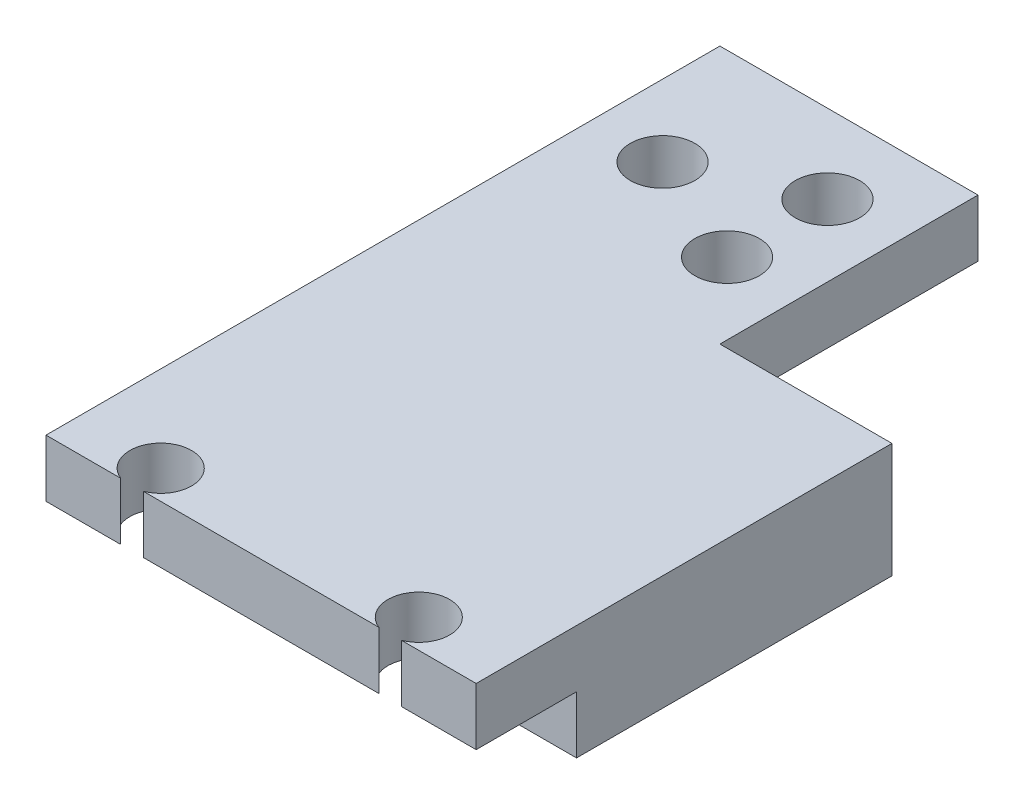
from build123d import *

# Parameters (mm, degrees)
BOSS_EXTRUDE1_DEPTH = 4
SKETCH2_W           = 30
SKETCH2_H           = 22
BOSS_EXTRUDE2_DEPTH = 4
SKETCH3_W           = 30
SKETCH3_H           = 4
BOSS_EXTRUDE3_DEPTH = 18
CUT_EXTRUDE1_REACH  = 6
SKETCH4_R           = 2.25
CUT_EXTRUDE2_REACH  = 6
SKETCH5_W           = 12
SKETCH5_H           = 18


with BuildPart() as part:
    # Sketch1 → Boss-Extrude1 (new body)
    with BuildSketch(Plane(origin=(0, 0, 0), x_dir=(1, 0, 0), z_dir=(0, 1, 0))):
        with BuildLine():
            Line((-15, -14.5), (-9.788986692, -14.5))
            ThreePointArc((-9.788986692, -14.5), (-9, -10.35), (-8.211013308, -14.5))
            Line((-8.211013308, -14.5), (8.211013308, -14.5))
            ThreePointArc((8.211013308, -14.5), (9, -10.35), (9.788986692, -14.5))
            Line((9.788986692, -14.5), (15, -14.5))
            Line((15, -14.5), (15, 14.5))
            Line((15, 14.5), (-15, 14.5))
            Line((-15, 14.5), (-15, -14.5))
        make_face()
    extrude(amount=BOSS_EXTRUDE1_DEPTH)

    # Sketch2 → Boss-Extrude2 (add)
    with BuildSketch(Plane.XZ):
        with Locations((0, -3.5)):
            Rectangle(SKETCH2_W, SKETCH2_H)
    extrude(amount=BOSS_EXTRUDE2_DEPTH)

    # Sketch3 → Boss-Extrude3 (add)
    with BuildSketch(Plane(origin=(0, 0, -14.5), x_dir=(-1, 0, 0), z_dir=(0, 0, -1))):
        with Locations((0, 2)):
            Rectangle(SKETCH3_W, SKETCH3_H)
    extrude(amount=BOSS_EXTRUDE3_DEPTH)

    # Sketch4 → Cut-Extrude1 (cut, up to next)
    with BuildSketch(Plane(origin=(0, 0, 0), x_dir=(-1, 0, 0), z_dir=(0, 1, 0)), mode=Mode.PRIVATE) as cut_extrude1_sk1:
        with Locations((2, -27)):
            Circle(SKETCH4_R)
    cut_extrude1_tool1 = extrude(cut_extrude1_sk1.sketch, amount=CUT_EXTRUDE1_REACH, mode=Mode.PRIVATE) & part.part
    add(cut_extrude1_tool1.solids().sort_by_distance((-2, 0, -27))[0], mode=Mode.SUBTRACT)
    # Sketch4 → Cut-Extrude1 (cut, up to next)
    with BuildSketch(Plane(origin=(0, 0, 0), x_dir=(-1, 0, 0), z_dir=(0, 1, 0)), mode=Mode.PRIVATE) as cut_extrude1_sk2:
        with Locations((10, -23.5)):
            Circle(SKETCH4_R)
    cut_extrude1_tool2 = extrude(cut_extrude1_sk2.sketch, amount=CUT_EXTRUDE1_REACH, mode=Mode.PRIVATE) & part.part
    add(cut_extrude1_tool2.solids().sort_by_distance((-10, 0, -23.5))[0], mode=Mode.SUBTRACT)
    # Sketch4 → Cut-Extrude1 (cut, up to next)
    with BuildSketch(Plane(origin=(0, 0, 0), x_dir=(-1, 0, 0), z_dir=(0, 1, 0)), mode=Mode.PRIVATE) as cut_extrude1_sk3:
        with Locations((2, -20)):
            Circle(SKETCH4_R)
    cut_extrude1_tool3 = extrude(cut_extrude1_sk3.sketch, amount=CUT_EXTRUDE1_REACH, mode=Mode.PRIVATE) & part.part
    add(cut_extrude1_tool3.solids().sort_by_distance((-2, 0, -20))[0], mode=Mode.SUBTRACT)

    # Sketch5 → Cut-Extrude2 (cut, up to next)
    with BuildSketch(Plane(origin=(0, 0, 0), x_dir=(1, 0, 0), z_dir=(0, 1, 0)), mode=Mode.PRIVATE) as cut_extrude2_sk1:
        with Locations((9, 23.5)):
            Rectangle(SKETCH5_W, SKETCH5_H)
    cut_extrude2_tool1 = extrude(cut_extrude2_sk1.sketch, amount=CUT_EXTRUDE2_REACH, mode=Mode.PRIVATE) & part.part
    add(cut_extrude2_tool1.solids().sort_by_distance((9, 0, -23.5))[0], mode=Mode.SUBTRACT)


solid = part.part
